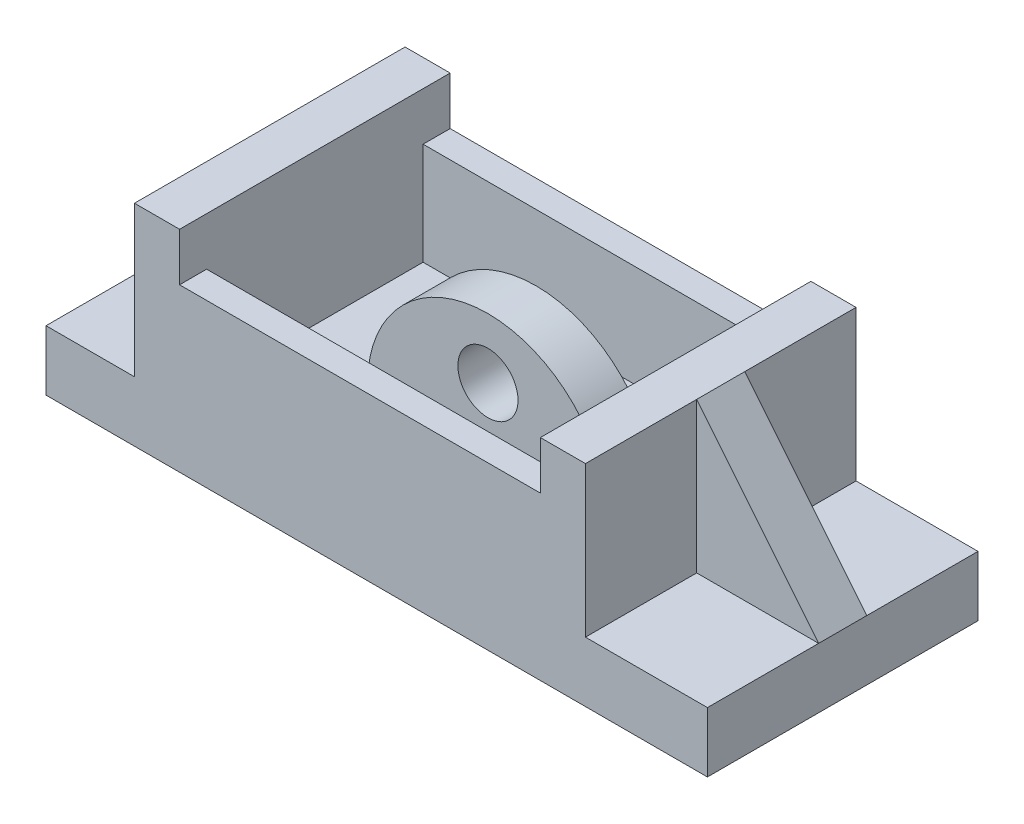
from build123d import *

# Parameters (mm, degrees)
SKETCH3_W             = 14.715370019
SKETCH3_H             = 45
BOSS_EXTRUDE4_DEPTH   = 10
SKETCH3_W_2           = 60
SKETCH3_H_2           = 36
BOSS_EXTRUDE4_2_DEPTH = 10
SKETCH3_W_3           = 20.284629981
BOSS_EXTRUDE4_3_DEPTH = 10
SKETCH3_3_W           = 7.5
SKETCH3_3_H           = 45
BOSS_EXTRUDE5_DEPTH   = 35
SKETCH3_4_W           = 60
SKETCH3_4_H           = 4.5
BOSS_EXTRUDE6_DEPTH   = 27
SKETCH4_R             = 5
BOSS_EXTRUDE7_DEPTH   = 4
RIB1_REACH            = 70.966
SKETCH5_WALL_W        = 168.940487542
SKETCH5_WALL_H        = 8
RIB2_REACH            = 70.966
SKETCH6_WALL_W        = 172.12533758
SKETCH6_WALL_H        = 8


with BuildPart() as part:
    # Sketch3 → Boss-Extrude4 (new body)
    with BuildSketch(Plane(origin=(0, 0, 0), x_dir=(1, 0, 0), z_dir=(0, 1, 0))):
        with Locations((-47.64231499, 0)):
            Rectangle(SKETCH3_W, SKETCH3_H)
    extrude(amount=BOSS_EXTRUDE4_DEPTH)



with BuildPart() as body_2:
    # Sketch3 → Boss-Extrude4 2 (new body)
    with BuildSketch(Plane(origin=(0, 0, 0), x_dir=(1, 0, 0), z_dir=(0, 1, 0))):
        with Locations((-2.784629981, 0)):
            Rectangle(SKETCH3_W_2, SKETCH3_H_2)
    extrude(amount=BOSS_EXTRUDE4_2_DEPTH)


with BuildPart() as body_3:
    # Sketch3 → Boss-Extrude4 3 (new body)
    with BuildSketch(Plane(origin=(0, 0, 0), x_dir=(1, 0, 0), z_dir=(0, 1, 0))):
        with Locations((44.85768501, 0)):
            Rectangle(SKETCH3_W_3, SKETCH3_H)
    extrude(amount=BOSS_EXTRUDE4_3_DEPTH)


with BuildPart() as part_1:
    add(part.part)

    add(body_2.part)  # Boss-Extrude5 merges body 2

    add(body_3.part)  # Boss-Extrude5 merges body 3
    # Sketch3_3 → Boss-Extrude5 (add)
    with BuildSketch(Plane(origin=(0, 0, 0), x_dir=(1, 0, 0), z_dir=(0, 1, 0))):
        with Locations((-36.534629981, 0)):
            Rectangle(SKETCH3_3_W, SKETCH3_3_H)
        with Locations((30.965370019, 0)):
            Rectangle(SKETCH3_3_W, SKETCH3_3_H)
    extrude(amount=BOSS_EXTRUDE5_DEPTH)

    # Sketch3_4 → Boss-Extrude6 (add)
    with BuildSketch(Plane(origin=(0, 0, 0), x_dir=(1, 0, 0), z_dir=(0, 1, 0))):
        with Locations((-2.784629981, 20.25)):
            Rectangle(SKETCH3_4_W, SKETCH3_4_H)
        with Locations((-2.784629981, -20.25)):
            Rectangle(SKETCH3_4_W, SKETCH3_4_H)
    extrude(amount=BOSS_EXTRUDE6_DEPTH)

    # Sketch4 → Boss-Extrude7 (add, symmetric)
    with BuildSketch(Plane.XY):
        with BuildLine():
            Line((-20, 10), (20, 10))
            ThreePointArc((20, 10), (0, 30), (-20, 10))
        make_face()
        with Locations((0, 20)):
            Circle(SKETCH4_R, mode=Mode.SUBTRACT)
    extrude(amount=BOSS_EXTRUDE7_DEPTH, both=True)

    # Sketch5 wall → Rib1 (add, up to next)
    with BuildSketch(Plane(origin=(-47.64231499, 22.5, 0), x_dir=(-0.507263085957, -0.861791251769, 0), z_dir=(0.861791251769, -0.507263085957, 0)), mode=Mode.PRIVATE) as rib1_sk1:
        Rectangle(SKETCH5_WALL_W, SKETCH5_WALL_H)
    rib1_tool1 = extrude(rib1_sk1.sketch, amount=RIB1_REACH, mode=Mode.PRIVATE) - part_1.part
    add(rib1_tool1.solids().sort_by_distance((-47.64231499, 22.5, 0))[0])

    # Sketch6 wall → Rib2 (add, up to next)
    with BuildSketch(Plane(origin=(44.85768501, 22.5, 0), x_dir=(0.630071035104, -0.77653750117, 0), z_dir=(0.77653750117, 0.630071035104, 0)), mode=Mode.PRIVATE) as rib2_sk1:
        Rectangle(SKETCH6_WALL_W, SKETCH6_WALL_H)
    rib2_tool1 = extrude(rib2_sk1.sketch, amount=-RIB2_REACH, mode=Mode.PRIVATE) - part_1.part
    add(rib2_tool1.solids().sort_by_distance((44.85768501, 22.5, 0))[0])


solid = part_1.part
